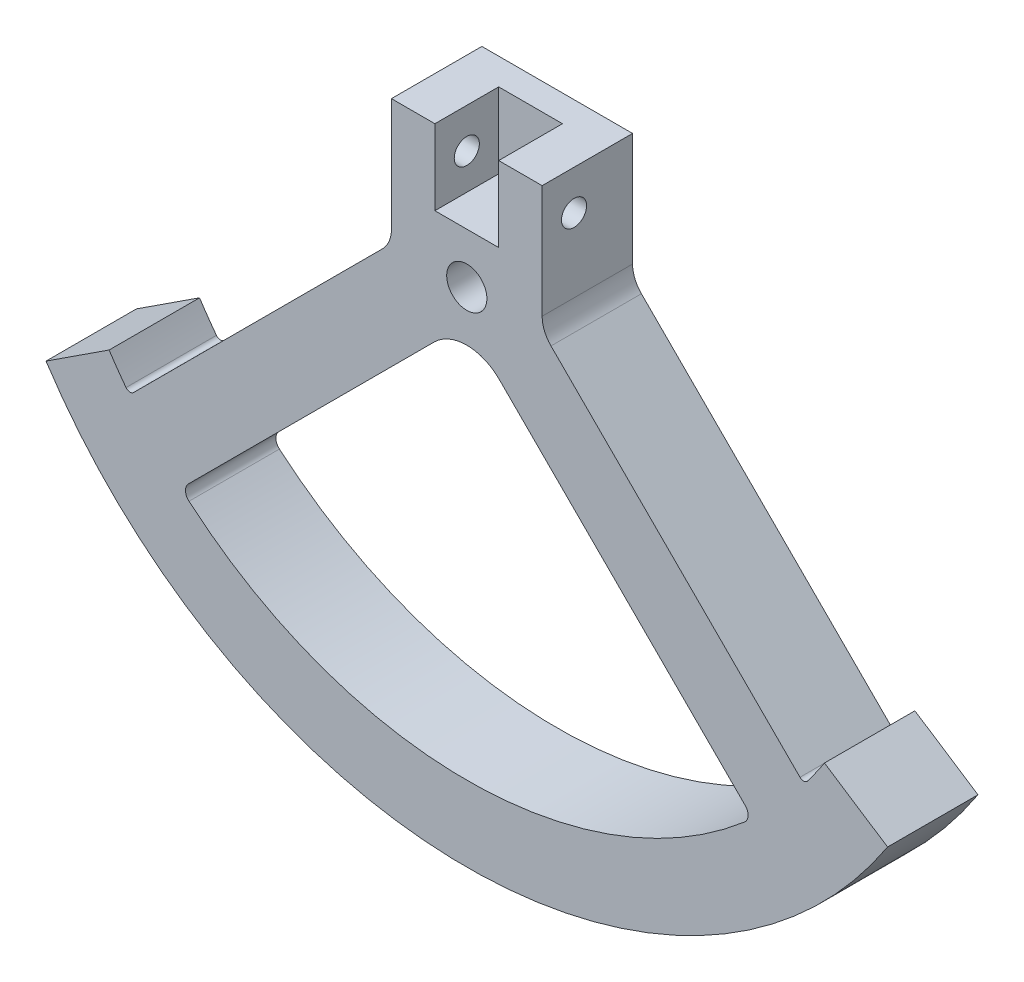
from build123d import *

# Parameters (mm, degrees)
ESQUISSE1_R             = 4
BOSS_EXTRU_1_DEPTH      = 18
ESQUISSE2_W             = 12.7
ESQUISSE2_H             = 12.7
ENL_V_MAT_EXTRU_1_DEPTH = 15
ESQUISSE3_R             = 2.5
ENL_V_MAT_EXTRU_2_DEPTH = 30
CONG_1_R                = 1
CONG_2_R                = 6


with BuildPart() as part:
    # Esquisse1 → Boss.-Extru.1 (new body)
    with BuildSketch(Plane.XY):
        with BuildLine():
            Line((15, 25), (-15, 25))
            Line((-15, 25), (-15, 0))
            Line((-15, 0), (-67.134302209, -52.134302209))
            ThreePointArc((-67.134302209, -52.134302209), (-69.224071464, -49.325732939), (-71.196421393, -46.433496324))
            Line((-71.196421393, -46.433496324), (-83.760495756, -54.627642734))
            ThreePointArc((-83.760495756, -54.627642734), (0, -100), (83.760495756, -54.627642734))
            Line((83.760495756, -54.627642734), (71.196421393, -46.433496324))
            ThreePointArc((71.196421393, -46.433496324), (69.224071464, -49.325732939), (67.134302209, -52.134302209))
            Line((67.134302209, -52.134302209), (15, 0))
            Line((15, 0), (15, 25))
        make_face()
        Circle(ESQUISSE1_R, mode=Mode.SUBTRACT)
        with BuildLine():
            Line((-55.408885371, -61.622088806), (-6.464466094, -12.67766953))
            ThreePointArc((-6.464466094, -12.67766953), (0, -10), (6.464466094, -12.67766953))
            Line((6.464466094, -12.67766953), (55.408885371, -61.622088806))
            ThreePointArc((55.408885371, -61.622088806), (55.993185687, -63.113388543), (55.295748237, -64.555249414))
            ThreePointArc((55.295748237, -64.555249414), (0, -85), (-55.295748237, -64.555249414))
            ThreePointArc((-55.295748237, -64.555249414), (-55.993185687, -63.113388543), (-55.408885371, -61.622088806))
        make_face(mode=Mode.SUBTRACT)
    extrude(amount=BOSS_EXTRU_1_DEPTH)

    # Esquisse2 → Enlèv. mat.-Extru.1 (cut)
    with BuildSketch(Plane(origin=(0, 25, 0), x_dir=(1, 0, 0), z_dir=(0, 1, 0))):
        with Locations((0, -11.65)):
            Rectangle(ESQUISSE2_W, ESQUISSE2_H)
    extrude(amount=-ENL_V_MAT_EXTRU_1_DEPTH, mode=Mode.SUBTRACT)

    # Esquisse3 → Enlèv. mat.-Extru.2 (cut)
    with BuildSketch(Plane.ZY.offset(15)):
        with Locations((11.65, 17.125)):
            Circle(ESQUISSE3_R)
    extrude(amount=-ENL_V_MAT_EXTRU_2_DEPTH, mode=Mode.SUBTRACT)

    # Congé1
    cong_1_edges = [part.edges().sort_by_distance(p)[0] for p in [
        (67.134302209, -52.134302209, 9),
        (-67.134302209, -52.134302209, 9),
    ]]
    fillet(cong_1_edges, radius=CONG_1_R)

    # Congé2
    cong_2_edges = [part.edges().sort_by_distance(p)[0] for p in [
        (15, 0, 9),
        (-15, 0, 9),
    ]]
    fillet(cong_2_edges, radius=CONG_2_R)


solid = part.part
